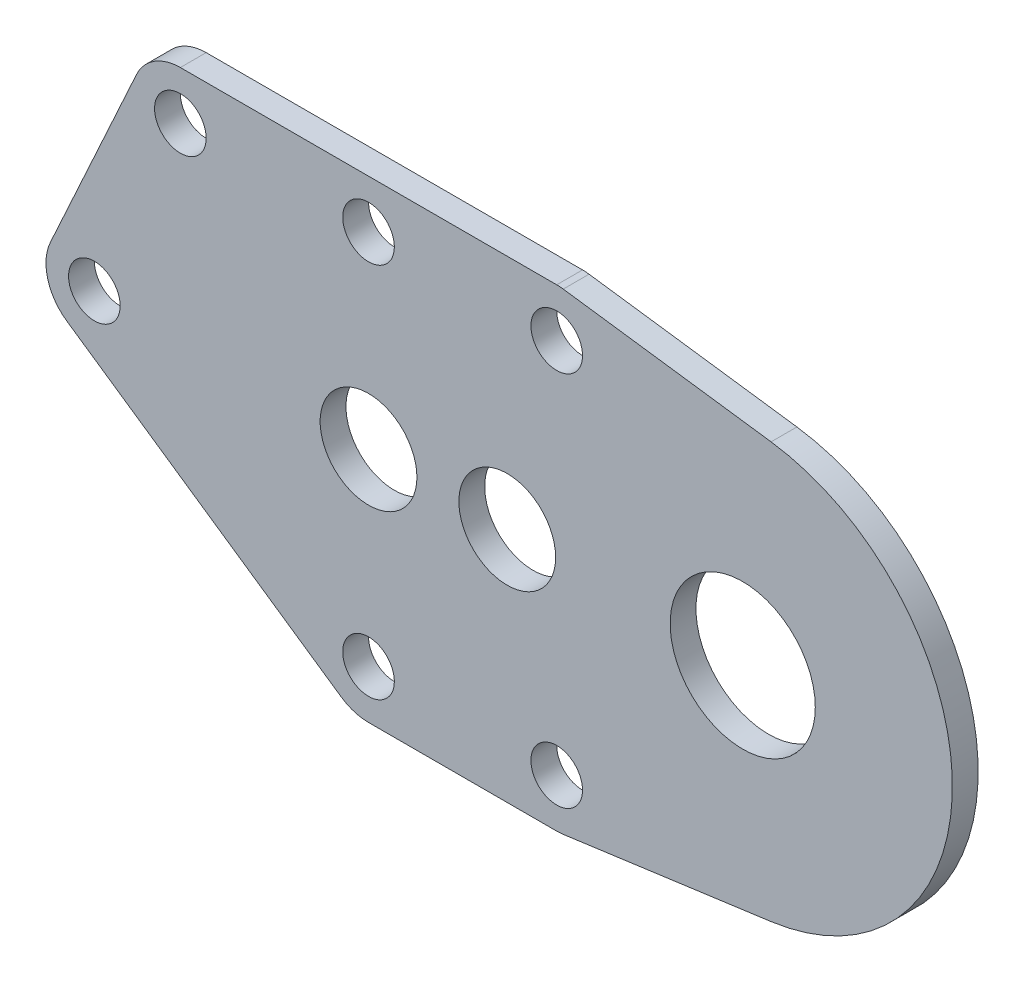
from build123d import *

# Parameters (mm, degrees)
SKETCH1_R           = 3
SKETCH1_R_2         = 4.5
SKETCH1_R_3         = 1.6
BOSS_EXTRUDE3_DEPTH = 1.6


with BuildPart() as part:
    # Sketch1 → Boss-Extrude3 (new body)
    with BuildSketch(Plane.XY):
        with BuildLine():
            Line((12.073070054, 14.639688463), (24.958502044, 12.880515151))
            ThreePointArc((24.958502044, 12.880515151), (36.2, 0), (24.958502044, -12.880515151))
            Line((24.958502044, -12.880515151), (12.073070054, -14.639688463))
            ThreePointArc((12.073070054, -14.639688463), (11.870633815, -14.660360595), (11.66726189, -14.66726189))
            Line((11.66726189, -14.66726189), (0, -14.66726189))
            ThreePointArc((0, -14.66726189), (-0.888679088, -14.53261518), (-1.697586366, -14.140761542))
            Line((-1.697586366, -14.140761542), (-18.697586366, -2.473499652))
            ThreePointArc((-18.697586366, -2.473499652), (-19.891071988, -0.801063519), (-19.728500117, 1.247111507))
            Line((-19.728500117, 1.247111507), (-14.395762007, 12.914373397))
            ThreePointArc((-14.395762007, 12.914373397), (-13.288783625, 14.191279968), (-11.66726189, 14.66726189))
            Line((-11.66726189, 14.66726189), (11.66726189, 14.66726189))
            ThreePointArc((11.66726189, 14.66726189), (11.870633815, 14.660360595), (12.073070054, 14.639688463))
        make_face()
        Circle(SKETCH1_R, mode=Mode.SUBTRACT)
        with Locations((23.2, 0)):
            Circle(SKETCH1_R_2, mode=Mode.SUBTRACT)
        with Locations((8.6, 0)):
            Circle(SKETCH1_R, mode=Mode.SUBTRACT)
        with Locations((-17, 0)):
            Circle(SKETCH1_R_3, mode=Mode.SUBTRACT)
        with Locations((0, -11.66726189)):
            Circle(SKETCH1_R_3, mode=Mode.SUBTRACT)
        with Locations((11.66726189, -11.66726189)):
            Circle(SKETCH1_R_3, mode=Mode.SUBTRACT)
        with Locations((-11.66726189, 11.66726189)):
            Circle(SKETCH1_R_3, mode=Mode.SUBTRACT)
        with Locations((0, 11.66726189)):
            Circle(SKETCH1_R_3, mode=Mode.SUBTRACT)
        with Locations((11.66726189, 11.66726189)):
            Circle(SKETCH1_R_3, mode=Mode.SUBTRACT)
    extrude(amount=BOSS_EXTRUDE3_DEPTH)


solid = part.part
